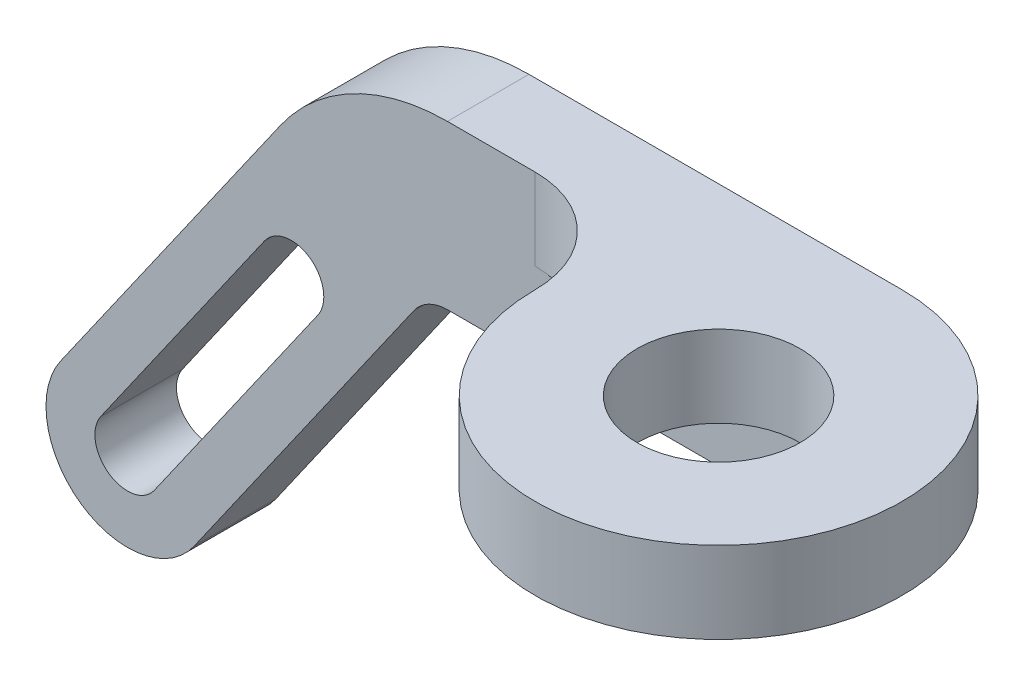
from build123d import *

# Parameters (mm, degrees)
EXTRUDE1_DEPTH                                 = 5
SKETCH2_R                                      = 10
EXTRUDE2_DEPTH                                 = 10
BROCA_DE_ROSQUEAR_PARA_TARRAXA_DE_M2_2X0_D     = 1.75
BROCA_DE_ROSQUEAR_PARA_TARRAXA_DE_M2_2X0_DEPTH = 5
BROCA_DE_ROSQUEAR_PARA_TARRAXA_DE_M2_2X0_TIP   = 0.525753042


with BuildPart() as part:
    # Sketch1 → Extrude1 (new body, symmetric)
    with BuildSketch(Plane.XY):
        with BuildLine():
            Line((11.498532289, 11.006151708), (-15.451429048, -27.482381858))
            ThreePointArc((-15.451429048, -27.482381858), (-29.378713855, -29.938137938), (-31.834469934, -16.010853131))
            Line((-31.834469934, -16.010853131), (-4.884508596, 22.477680435))
            ThreePointArc((-4.884508596, 22.477680435), (4.05057718, 30.313540355), (15.594292511, 33.138269526))
            Line((15.594292511, 33.138269526), (61.357050509, 33.138269526))
            Line((61.357050509, 33.138269526), (61.357050509, 13.138269526))
            Line((61.357050509, 13.138269526), (15.594292511, 13.138269526))
            ThreePointArc((15.594292511, 13.138269526), (13.285549445, 12.573323692), (11.498532289, 11.006151708))
        make_face()
        with BuildLine():
            Line((-26.919557668, -19.45231175), (-6.844382396, 9.218009801))
            ThreePointArc((-6.844382396, 9.218009801), (-1.273468473, 10.200312232), (-0.291166042, 4.62939831))
            Line((-0.291166042, 4.62939831), (-20.366341314, -24.04092324))
            ThreePointArc((-20.366341314, -24.04092324), (-25.937255237, -25.023225672), (-26.919557668, -19.45231175))
        make_face(mode=Mode.SUBTRACT)
    extrude(amount=EXTRUDE1_DEPTH, both=True)

    # Sketch2 → Extrude2 (add)
    with BuildSketch(Plane(origin=(0, 33.138269526, 0), x_dir=(1, 0, 0), z_dir=(0, 1, 0))):
        with BuildLine():
            Line((61.357050509, 5), (15.594292511, 5))
            Line((15.594292511, 5), (15.594292511, -5))
            Line((15.594292511, -5), (26.357050509, -5))
            ThreePointArc((26.357050509, -5), (35.195885274, -8.661165235), (38.857050509, -17.5))
            ThreePointArc((38.857050509, -17.5), (77.266953086, -33.409902577), (61.357050509, 5))
        make_face()
        with Locations(Location((61.357050509, -17.5, 0), (0, 0, 180))):  # turned: the seam where the file's is
            Circle(SKETCH2_R, mode=Mode.SUBTRACT)
    extrude(amount=-EXTRUDE2_DEPTH)

    # Broca de rosquear para tarraxa de M2.2x0.451
    with Locations(Plane(origin=(61.357050509, 18.138269526, 0), x_dir=(0, 1, 0), z_dir=(1, 0, 0))):
        with Locations((0, 0)):
            Hole(BROCA_DE_ROSQUEAR_PARA_TARRAXA_DE_M2_2X0_D / 2, depth=BROCA_DE_ROSQUEAR_PARA_TARRAXA_DE_M2_2X0_DEPTH)
            with Locations((0, 0, -(BROCA_DE_ROSQUEAR_PARA_TARRAXA_DE_M2_2X0_DEPTH + BROCA_DE_ROSQUEAR_PARA_TARRAXA_DE_M2_2X0_TIP / 2))):  # 118° drill point
                Cone(0, BROCA_DE_ROSQUEAR_PARA_TARRAXA_DE_M2_2X0_D / 2, BROCA_DE_ROSQUEAR_PARA_TARRAXA_DE_M2_2X0_TIP, mode=Mode.SUBTRACT)


solid = part.part
